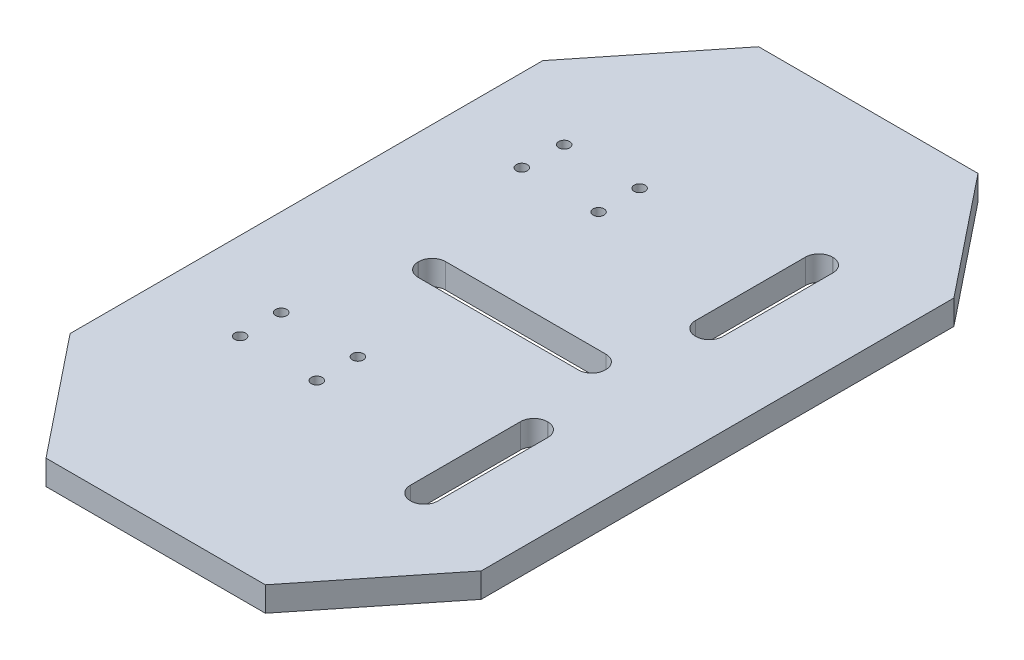
from build123d import *

# Parameters (mm, degrees)
BOSS_EXTRUDE1_DEPTH = 4.5
CUT_EXTRUDE2_DEPTH  = 10
SKETCH7_R           = 1
CUT_EXTRUDE3_DEPTH  = 5
SKETCH11_R          = 2
SKETCH11_R_2        = 1
CUT_EXTRUDE4_DEPTH  = 1.65


with BuildPart() as part:
    # Sketch1 → Boss-Extrude1 (new body)
    with BuildSketch(Plane(origin=(0, 0, 0), x_dir=(1, 0, 0), z_dir=(0, 1, 0))):
        Polygon((-37.5, -43.117707706), (-20.011895516, -65), (20.011895516, -65), (37.5, -43.117707706), (37.5, 43.117707706), (20.011895516, 65), (-20.011895516, 65), (-37.5, 43.117707706), align=None)
    extrude(amount=BOSS_EXTRUDE1_DEPTH)

    # Sketch5 → Cut-Extrude2 (cut)
    with BuildSketch(Plane(origin=(0, 4.5, 0), x_dir=(1, 0, 0), z_dir=(0, 1, 0))):
        with BuildLine():
            Line((-14.620176413, -2.5), (14.620176413, -2.5))
            ThreePointArc((14.620176413, -2.5), (16.352588027, -1.782411614), (17.070176413, -0.05))
            Line((17.070176413, -0.05), (17.070176413, 0.05))
            ThreePointArc((17.070176413, 0.05), (16.352588027, 1.782411614), (14.620176413, 2.5))
            Line((14.620176413, 2.5), (-14.620176413, 2.5))
            ThreePointArc((-14.620176413, 2.5), (-16.352588027, 1.782411614), (-17.070176413, 0.05))
            Line((-17.070176413, 0.05), (-17.070176413, -0.05))
            ThreePointArc((-17.070176413, -0.05), (-16.352588027, -1.782411614), (-14.620176413, -2.5))
        make_face()
        with BuildLine():
            Line((19.95, -38.5), (20.05, -38.5))
            ThreePointArc((20.05, -38.5), (21.782411614, -37.782411614), (22.5, -36.05))
            Line((22.5, -36.05), (22.5, -15.95))
            ThreePointArc((22.5, -15.95), (21.782411614, -14.217588386), (20.05, -13.5))
            Line((20.05, -13.5), (19.95, -13.5))
            ThreePointArc((19.95, -13.5), (18.217588386, -14.217588386), (17.5, -15.95))
            Line((17.5, -15.95), (17.5, -36.05))
            ThreePointArc((17.5, -36.05), (18.217588386, -37.782411614), (19.95, -38.5))
        make_face()
        with BuildLine():
            Line((19.95, 13.5), (20.05, 13.5))
            ThreePointArc((20.05, 13.5), (21.782411614, 14.217588386), (22.5, 15.95))
            Line((22.5, 15.95), (22.5, 36.05))
            ThreePointArc((22.5, 36.05), (21.782411614, 37.782411614), (20.05, 38.5))
            Line((20.05, 38.5), (19.95, 38.5))
            ThreePointArc((19.95, 38.5), (18.217588386, 37.782411614), (17.5, 36.05))
            Line((17.5, 36.05), (17.5, 15.95))
            ThreePointArc((17.5, 15.95), (18.217588386, 14.217588386), (19.95, 13.5))
        make_face()
    extrude(amount=-CUT_EXTRUDE2_DEPTH, mode=Mode.SUBTRACT)

    # Sketch7 → Cut-Extrude3 (cut)
    with BuildSketch(Plane(origin=(0, 4.5, 0), x_dir=(1, 0, 0), z_dir=(0, 1, 0))):
        with Locations((-8.5, 24.29)):
            Circle(SKETCH7_R)
        with Locations((-22.5, 24.29)):
            Circle(SKETCH7_R)
        with Locations((-22.26760758, 31.79)):
            Circle(SKETCH7_R)
        with Locations((-21.57, -20.54)):
            Circle(SKETCH7_R)
        with Locations((-21.57, -28.04)):
            Circle(SKETCH7_R)
        with Locations((-7.57, -28.04)):
            Circle(SKETCH7_R)
        with Locations((-7.57, -20.54)):
            Circle(SKETCH7_R)
        with Locations((-8.5, 31.79)):
            Circle(SKETCH7_R)
    extrude(amount=-CUT_EXTRUDE3_DEPTH, mode=Mode.SUBTRACT)

    # Sketch11 → Cut-Extrude4 (cut)
    with BuildSketch(Plane.XZ):
        with Locations((-7.57, 20.54)):
            Circle(SKETCH11_R)
        with Locations((-7.57, 20.54)):
            Circle(SKETCH11_R_2, mode=Mode.SUBTRACT)
        with Locations((-21.57, 20.54)):
            Circle(SKETCH11_R)
        with Locations((-21.57, 20.54)):
            Circle(SKETCH11_R_2, mode=Mode.SUBTRACT)
        with Locations((-8.5, -24.29)):
            Circle(SKETCH11_R)
        with Locations((-8.5, -24.29)):
            Circle(SKETCH11_R_2, mode=Mode.SUBTRACT)
        with Locations((-8.5, -31.79)):
            Circle(SKETCH11_R)
        with Locations((-8.5, -31.79)):
            Circle(SKETCH11_R_2, mode=Mode.SUBTRACT)
        with Locations((-7.57, 28.04)):
            Circle(SKETCH11_R)
        with Locations((-21.57, 28.04)):
            Circle(SKETCH11_R)
        with Locations((-22.26760758, -31.79)):
            Circle(SKETCH11_R)
        with Locations((-22.5, -24.29)):
            Circle(SKETCH11_R)
    extrude(amount=-CUT_EXTRUDE4_DEPTH, mode=Mode.SUBTRACT)


solid = part.part
